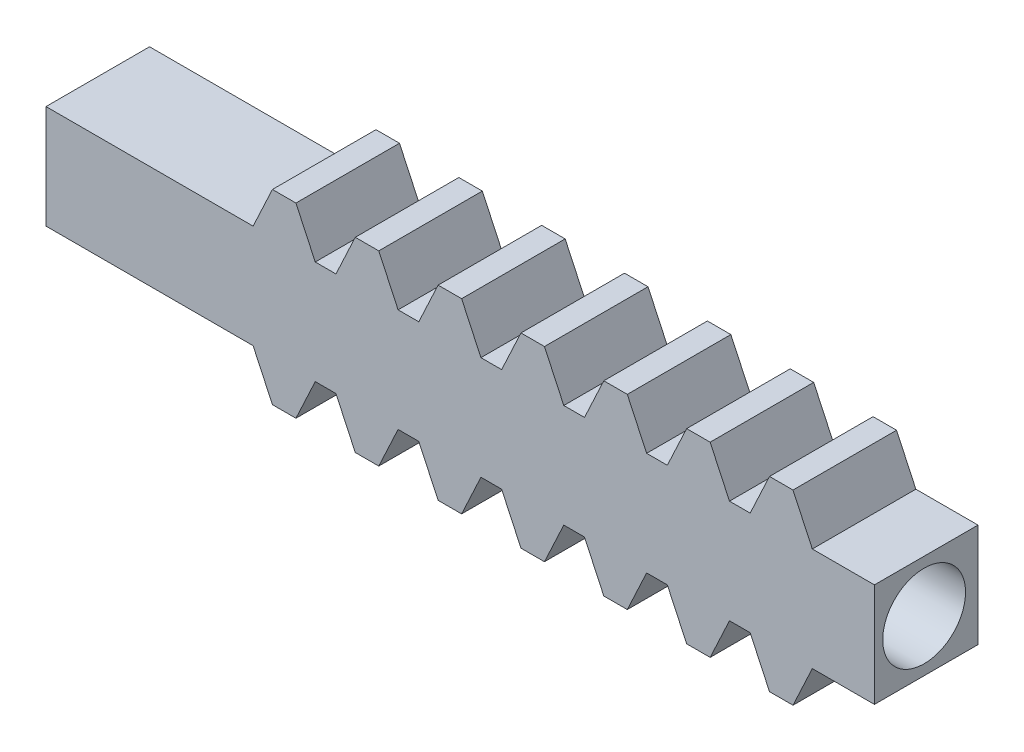
from build123d import *

# Parameters (mm, degrees)
BOSS_EXTRUDE1_DEPTH = 5
SKETCH3_R           = 2
CUT_EXTRUDE1_DEPTH  = 5
SKETCH4_R           = 1
CUT_EXTRUDE9_DEPTH  = 61


with BuildPart() as part:
    # Sketch1 → Boss-Extrude1 (new body)
    with BuildSketch(Plane.XY):
        Polygon((53, -5), (54, -5), (54.932615316, -7), (56.067384684, -7), (57, -5), (60, -5), (60, 0), (57, 0), (56.067384684, 2), (54.932615316, 2), (54, 0), (53, 0), (52.067384684, 2), (50.932615316, 2), (50, 0), (49, 0), (48.067384684, 2), (46.932615316, 2), (46, 0), (45, 0), (44.067384684, 2), (42.932615316, 2), (42, 0), (41, 0), (40.067384684, 2), (38.932615316, 2), (38, 0), (37, 0), (36.067384684, 2), (34.932615316, 2), (34, 0), (33, 0), (32.067384684, 2), (30.932615316, 2), (30, 0), (20, 0), (20, -5), (30, -5), (30.932615316, -7), (32.067384684, -7), (33, -5), (34, -5), (34.932615316, -7), (36.067384684, -7), (37, -5), (38, -5), (38.932615316, -7), (40.067384684, -7), (41, -5), (42, -5), (42.932615316, -7), (44.067384684, -7), (45, -5), (46, -5), (46.932615316, -7), (48.067384684, -7), (49, -5), (50, -5), (50.932615316, -7), (52.067384684, -7), align=None)
    extrude(amount=BOSS_EXTRUDE1_DEPTH)

    # Sketch3 → Cut-Extrude1 (cut)
    with BuildSketch(Plane(origin=(60, 0, 0), x_dir=(0, 0, -1), z_dir=(1, 0, 0))):
        with Locations((-2.601693616, -2.5)):
            Circle(SKETCH3_R)
    extrude(amount=-CUT_EXTRUDE1_DEPTH, mode=Mode.SUBTRACT)

    # Sketch4 → Cut-Extrude9 (cut, through all)
    with BuildSketch(Plane(origin=(0, 0, 0), x_dir=(0, 0, -1), z_dir=(1, 0, 0))):
        with Locations((-2.601693616, -2.5)):
            Circle(SKETCH4_R)
    extrude(amount=CUT_EXTRUDE9_DEPTH, mode=Mode.SUBTRACT)


solid = part.part
